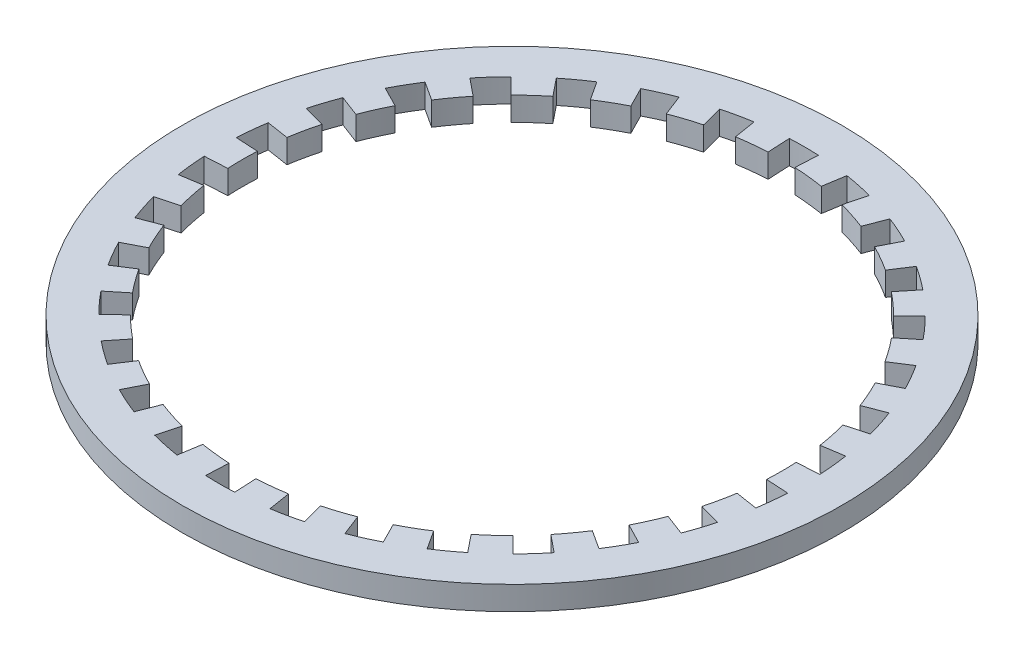
from build123d import *

# Parameters (mm, degrees)
SKETCH1_R           = 7.94
SKETCH1_R_2         = 6.5
BOSS_EXTRUDE1_DEPTH = 0.57
CUT_EXTRUDE1_DEPTH  = 1.57


with BuildPart() as part:
    # Sketch1 → Boss-Extrude1 (new body)
    with BuildSketch(Plane(origin=(0, 0, 0), x_dir=(1, 0, 0), z_dir=(0, 1, 0))):
        Circle(SKETCH1_R)
        Circle(SKETCH1_R_2, mode=Mode.SUBTRACT)
    extrude(amount=BOSS_EXTRUDE1_DEPTH)

    # Sketch2 → Cut-Extrude1 (cut, through all)
    with BuildSketch(Plane(origin=(0, 0.57, 0), x_dir=(1, 0, 0), z_dir=(0, 1, 0))):
        with BuildLine():
            Line((-0.35, 7.031294333), (-0.323153409, 6.491962097))
            ThreePointArc((-0.323153409, 6.491962097), (0, 6.5), (0.323153409, 6.491962097))
            Line((0.323153409, 6.491962097), (0.35, 7.031294333))
            ThreePointArc((0.35, 7.031294333), (0, 7.04), (-0.35, 7.031294333))
        make_face()
        with BuildLine():
            Line((1.804239954, 6.80487459), (1.665846548, 6.282909778))
            ThreePointArc((1.665846548, 6.282909778), (1.35142599, 6.357959405), (1.033663085, 6.417284521))
            Line((1.033663085, 6.417284521), (1.119536633, 6.950412774))
            ThreePointArc((1.119536633, 6.950412774), (1.463698303, 6.886159109), (1.804239954, 6.80487459))
        make_face()
        with BuildLine():
            Line((3.179625964, 6.281049174), (2.935734199, 5.799264152))
            ThreePointArc((2.935734199, 5.799264152), (2.64378818, 5.938045475), (2.345303541, 6.062140818))
            Line((2.345303541, 6.062140818), (2.540144143, 6.565764825))
            ThreePointArc((2.540144143, 6.565764825), (2.863425967, 6.431360022), (3.179625964, 6.281049174))
        make_face()
        with BuildLine():
            Line((4.416047062, 5.48271177), (4.077316179, 5.062162856))
            ThreePointArc((4.077316179, 5.062162856), (3.82060414, 5.258610463), (3.55444298, 5.442052472))
            Line((3.55444298, 5.442052472), (3.849735166, 5.894161446))
            ThreePointArc((3.849735166, 5.894161446), (4.138008176, 5.69547964), (4.416047062, 5.48271177))
        make_face()
        with BuildLine():
            Line((5.459465712, 4.444753552), (5.040699876, 4.103820751))
            ThreePointArc((5.040699876, 4.103820751), (4.830441366, 4.349348941), (4.608236203, 4.584120318))
            Line((4.608236203, 4.584120318), (4.991074288, 4.96495493))
            ThreePointArc((4.991074288, 4.96495493), (5.231739571, 4.710679469), (5.459465712, 4.444753552))
        make_face()
        with BuildLine():
            Line((6.264279514, 3.212538275), (5.783780801, 2.966121987))
            ThreePointArc((5.783780801, 2.966121987), (5.629165125, 3.25), (5.460627392, 3.52584011))
            Line((5.460627392, 3.52584011), (5.914279514, 3.818756058))
            ThreePointArc((5.914279514, 3.818756058), (6.096818843, 3.52), (6.264279514, 3.212538275))
        make_face()
        with BuildLine():
            Line((6.795314242, 1.839919661), (6.274082751, 1.698789459))
            ThreePointArc((6.274082751, 1.698789459), (6.181867356, 2.008610463), (6.074362961, 2.31346377))
            Line((6.074362961, 2.31346377), (6.579002346, 2.505659222))
            ThreePointArc((6.579002346, 2.505659222), (6.695437875, 2.17547964), (6.795314242, 1.839919661))
        make_face()
        with BuildLine():
            Line((7.029361129, 0.386887728), (6.490177179, 0.357211681))
            ThreePointArc((6.490177179, 0.357211681), (6.46439232, 0.679435011), (6.422619721, 0.999977963))
            Line((6.422619721, 0.999977963), (6.956191205, 1.083053055))
            ThreePointArc((6.956191205, 1.083053055), (7.001434143, 0.735880381), (7.029361129, 0.386887728))
        make_face()
        with BuildLine():
            Line((6.956191205, -1.083053055), (6.422619721, -0.999977963))
            ThreePointArc((6.422619721, -0.999977963), (6.46439232, -0.679435011), (6.490177179, -0.357211681))
            Line((6.490177179, -0.357211681), (7.029361129, -0.386887728))
            ThreePointArc((7.029361129, -0.386887728), (7.001434143, -0.735880381), (6.956191205, -1.083053055))
        make_face()
        with BuildLine():
            Line((6.579002346, -2.505659222), (6.074362961, -2.31346377))
            ThreePointArc((6.074362961, -2.31346377), (6.181867356, -2.008610463), (6.274082751, -1.698789459))
            Line((6.274082751, -1.698789459), (6.795314242, -1.839919661))
            ThreePointArc((6.795314242, -1.839919661), (6.695437875, -2.17547964), (6.579002346, -2.505659222))
        make_face()
        with BuildLine():
            Line((5.914279514, -3.818756058), (5.460627392, -3.52584011))
            ThreePointArc((5.460627392, -3.52584011), (5.629165125, -3.25), (5.783780801, -2.966121987))
            Line((5.783780801, -2.966121987), (6.264279514, -3.212538275))
            ThreePointArc((6.264279514, -3.212538275), (6.096818843, -3.52), (5.914279514, -3.818756058))
        make_face()
        with BuildLine():
            Line((4.991074288, -4.96495493), (4.608236203, -4.584120318))
            ThreePointArc((4.608236203, -4.584120318), (4.830441366, -4.349348941), (5.040699876, -4.103820751))
            Line((5.040699876, -4.103820751), (5.459465712, -4.444753552))
            ThreePointArc((5.459465712, -4.444753552), (5.231739571, -4.710679469), (4.991074288, -4.96495493))
        make_face()
        with BuildLine():
            Line((3.849735166, -5.894161446), (3.55444298, -5.442052472))
            ThreePointArc((3.55444298, -5.442052472), (3.82060414, -5.258610463), (4.077316179, -5.062162856))
            Line((4.077316179, -5.062162856), (4.416047062, -5.48271177))
            ThreePointArc((4.416047062, -5.48271177), (4.138008176, -5.69547964), (3.849735166, -5.894161446))
        make_face()
        with BuildLine():
            Line((2.540144143, -6.565764825), (2.345303541, -6.062140818))
            ThreePointArc((2.345303541, -6.062140818), (2.64378818, -5.938045475), (2.935734199, -5.799264152))
            Line((2.935734199, -5.799264152), (3.179625964, -6.281049174))
            ThreePointArc((3.179625964, -6.281049174), (2.863425967, -6.431360022), (2.540144143, -6.565764825))
        make_face()
        with BuildLine():
            Line((1.119536633, -6.950412774), (1.033663085, -6.417284521))
            ThreePointArc((1.033663085, -6.417284521), (1.35142599, -6.357959405), (1.665846548, -6.282909778))
            Line((1.665846548, -6.282909778), (1.804239954, -6.80487459))
            ThreePointArc((1.804239954, -6.80487459), (1.463698303, -6.886159109), (1.119536633, -6.950412774))
        make_face()
        with BuildLine():
            Line((-0.35, -7.031294333), (-0.323153409, -6.491962097))
            ThreePointArc((-0.323153409, -6.491962097), (0, -6.5), (0.323153409, -6.491962097))
            Line((0.323153409, -6.491962097), (0.35, -7.031294333))
            ThreePointArc((0.35, -7.031294333), (0, -7.04), (-0.35, -7.031294333))
        make_face()
        with BuildLine():
            Line((-1.804239954, -6.80487459), (-1.665846548, -6.282909778))
            ThreePointArc((-1.665846548, -6.282909778), (-1.35142599, -6.357959405), (-1.033663085, -6.417284521))
            Line((-1.033663085, -6.417284521), (-1.119536633, -6.950412774))
            ThreePointArc((-1.119536633, -6.950412774), (-1.463698303, -6.886159109), (-1.804239954, -6.80487459))
        make_face()
        with BuildLine():
            Line((-3.179625964, -6.281049174), (-2.935734199, -5.799264152))
            ThreePointArc((-2.935734199, -5.799264152), (-2.64378818, -5.938045475), (-2.345303541, -6.062140818))
            Line((-2.345303541, -6.062140818), (-2.540144143, -6.565764825))
            ThreePointArc((-2.540144143, -6.565764825), (-2.863425967, -6.431360022), (-3.179625964, -6.281049174))
        make_face()
        with BuildLine():
            Line((-4.416047062, -5.48271177), (-4.077316179, -5.062162856))
            ThreePointArc((-4.077316179, -5.062162856), (-3.82060414, -5.258610463), (-3.55444298, -5.442052472))
            Line((-3.55444298, -5.442052472), (-3.849735166, -5.894161446))
            ThreePointArc((-3.849735166, -5.894161446), (-4.138008176, -5.69547964), (-4.416047062, -5.48271177))
        make_face()
        with BuildLine():
            Line((-5.459465712, -4.444753552), (-5.040699876, -4.103820751))
            ThreePointArc((-5.040699876, -4.103820751), (-4.830441366, -4.349348941), (-4.608236203, -4.584120318))
            Line((-4.608236203, -4.584120318), (-4.991074288, -4.96495493))
            ThreePointArc((-4.991074288, -4.96495493), (-5.231739571, -4.710679469), (-5.459465712, -4.444753552))
        make_face()
        with BuildLine():
            Line((-6.264279514, -3.212538275), (-5.783780801, -2.966121987))
            ThreePointArc((-5.783780801, -2.966121987), (-5.629165125, -3.25), (-5.460627392, -3.52584011))
            Line((-5.460627392, -3.52584011), (-5.914279514, -3.818756058))
            ThreePointArc((-5.914279514, -3.818756058), (-6.096818843, -3.52), (-6.264279514, -3.212538275))
        make_face()
        with BuildLine():
            Line((-6.795314242, -1.839919661), (-6.274082751, -1.698789459))
            ThreePointArc((-6.274082751, -1.698789459), (-6.181867356, -2.008610463), (-6.074362961, -2.31346377))
            Line((-6.074362961, -2.31346377), (-6.579002346, -2.505659222))
            ThreePointArc((-6.579002346, -2.505659222), (-6.695437875, -2.17547964), (-6.795314242, -1.839919661))
        make_face()
        with BuildLine():
            Line((-7.029361129, -0.386887728), (-6.490177179, -0.357211681))
            ThreePointArc((-6.490177179, -0.357211681), (-6.46439232, -0.679435011), (-6.422619721, -0.999977963))
            Line((-6.422619721, -0.999977963), (-6.956191205, -1.083053055))
            ThreePointArc((-6.956191205, -1.083053055), (-7.001434143, -0.735880381), (-7.029361129, -0.386887728))
        make_face()
        with BuildLine():
            Line((-6.956191205, 1.083053055), (-6.422619721, 0.999977963))
            ThreePointArc((-6.422619721, 0.999977963), (-6.46439232, 0.679435011), (-6.490177179, 0.357211681))
            Line((-6.490177179, 0.357211681), (-7.029361129, 0.386887728))
            ThreePointArc((-7.029361129, 0.386887728), (-7.001434143, 0.735880381), (-6.956191205, 1.083053055))
        make_face()
        with BuildLine():
            Line((-6.579002346, 2.505659222), (-6.074362961, 2.31346377))
            ThreePointArc((-6.074362961, 2.31346377), (-6.181867356, 2.008610463), (-6.274082751, 1.698789459))
            Line((-6.274082751, 1.698789459), (-6.795314242, 1.839919661))
            ThreePointArc((-6.795314242, 1.839919661), (-6.695437875, 2.17547964), (-6.579002346, 2.505659222))
        make_face()
        with BuildLine():
            Line((-5.914279514, 3.818756058), (-5.460627392, 3.52584011))
            ThreePointArc((-5.460627392, 3.52584011), (-5.629165125, 3.25), (-5.783780801, 2.966121987))
            Line((-5.783780801, 2.966121987), (-6.264279514, 3.212538275))
            ThreePointArc((-6.264279514, 3.212538275), (-6.096818843, 3.52), (-5.914279514, 3.818756058))
        make_face()
        with BuildLine():
            Line((-4.991074288, 4.96495493), (-4.608236203, 4.584120318))
            ThreePointArc((-4.608236203, 4.584120318), (-4.830441366, 4.349348941), (-5.040699876, 4.103820751))
            Line((-5.040699876, 4.103820751), (-5.459465712, 4.444753552))
            ThreePointArc((-5.459465712, 4.444753552), (-5.231739571, 4.710679469), (-4.991074288, 4.96495493))
        make_face()
        with BuildLine():
            Line((-3.849735166, 5.894161446), (-3.55444298, 5.442052472))
            ThreePointArc((-3.55444298, 5.442052472), (-3.82060414, 5.258610463), (-4.077316179, 5.062162856))
            Line((-4.077316179, 5.062162856), (-4.416047062, 5.48271177))
            ThreePointArc((-4.416047062, 5.48271177), (-4.138008176, 5.69547964), (-3.849735166, 5.894161446))
        make_face()
        with BuildLine():
            Line((-2.540144143, 6.565764825), (-2.345303541, 6.062140818))
            ThreePointArc((-2.345303541, 6.062140818), (-2.64378818, 5.938045475), (-2.935734199, 5.799264152))
            Line((-2.935734199, 5.799264152), (-3.179625964, 6.281049174))
            ThreePointArc((-3.179625964, 6.281049174), (-2.863425967, 6.431360022), (-2.540144143, 6.565764825))
        make_face()
        with BuildLine():
            Line((-1.119536633, 6.950412774), (-1.033663085, 6.417284521))
            ThreePointArc((-1.033663085, 6.417284521), (-1.35142599, 6.357959405), (-1.665846548, 6.282909778))
            Line((-1.665846548, 6.282909778), (-1.804239954, 6.80487459))
            ThreePointArc((-1.804239954, 6.80487459), (-1.463698303, 6.886159109), (-1.119536633, 6.950412774))
        make_face()
    extrude(amount=-CUT_EXTRUDE1_DEPTH, mode=Mode.SUBTRACT)


solid = part.part
